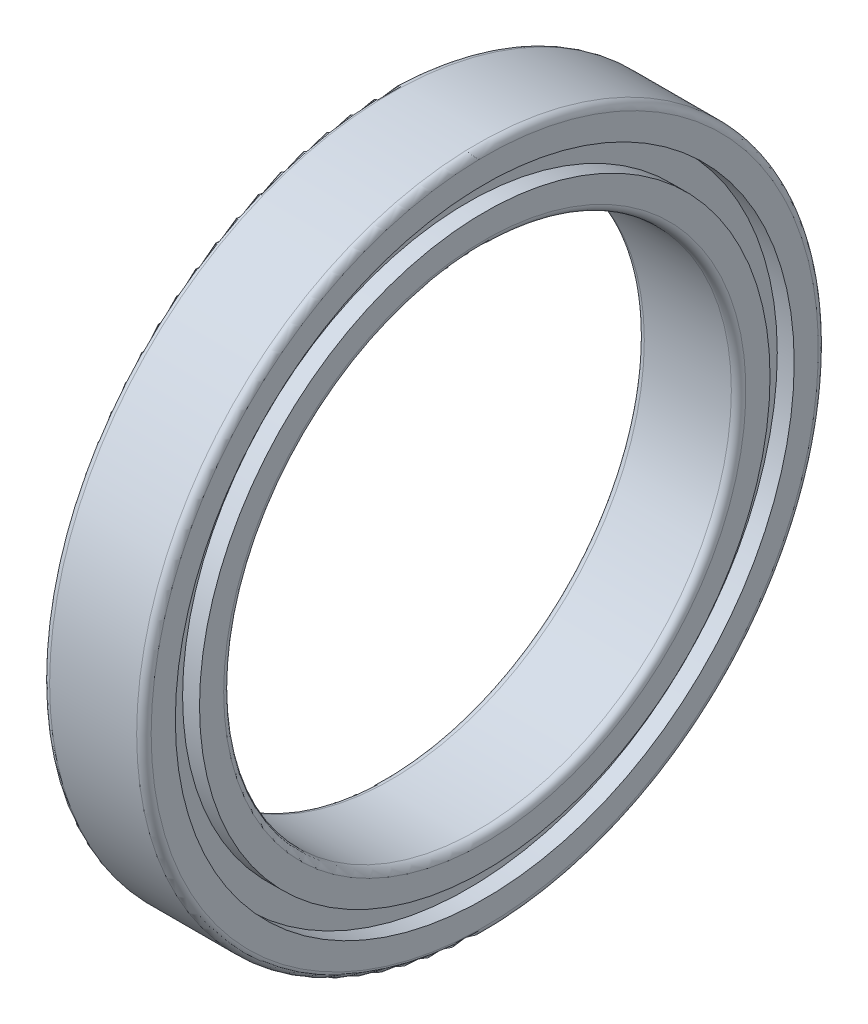
from build123d import *


with BuildPart() as part:
    # Эскиз1 → Повернуть1 (revolve)
    with BuildSketch(Plane.XY):
        with BuildLine():
            Line((3, 17.5), (-3, 17.5))
            ThreePointArc((-3, 17.5), (-3.353553391, 17.646446609), (-3.5, 18))
            Line((-3.5, 18), (-3.5, 19.666666667))
            Line((-3.5, 19.666666667), (-2.333333333, 19.666666667))
            Line((-2.333333333, 19.666666667), (-2.333333333, 21.333333333))
            Line((-2.333333333, 21.333333333), (-3.5, 21.333333333))
            Line((-3.5, 21.333333333), (-3.5, 23))
            ThreePointArc((-3.5, 23), (-3.353553391, 23.353553391), (-3, 23.5))
            Line((-3, 23.5), (3, 23.5))
            ThreePointArc((3, 23.5), (3.353553391, 23.353553391), (3.5, 23))
            Line((3.5, 23), (3.5, 21.333333333))
            Line((3.5, 21.333333333), (2.333333333, 21.333333333))
            Line((2.333333333, 21.333333333), (2.333333333, 19.666666667))
            Line((2.333333333, 19.666666667), (3.5, 19.666666667))
            Line((3.5, 19.666666667), (3.5, 18))
            ThreePointArc((3.5, 18), (3.353553391, 17.646446609), (3, 17.5))
        make_face()
    revolve(axis=Axis((-1000, 0, 0), (1, 0, 0)))


solid = part.part
